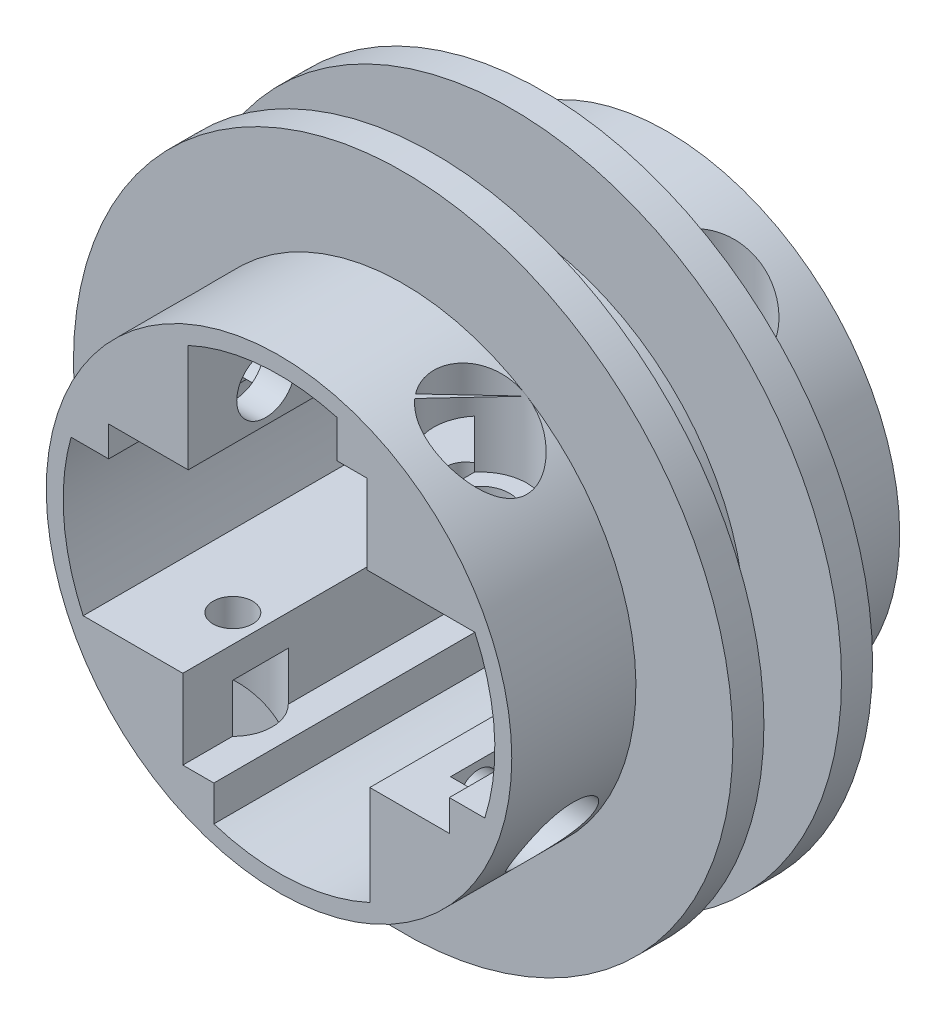
from build123d import *
from build123d.topology import SkipClean

# Parameters (mm, degrees)
SKETCH1_R            = 30
SKETCH1_R_2          = 27.819913731
BOSS_EXTRUDE2_DEPTH  = 16
SKETCH2_R            = 3.6
CUT_EXTRUDE1_DEPTH   = 16
SKETCH3_R            = 3.6
CUT_EXTRUDE2_DEPTH   = 16
SKETCH4_R            = 2.55
CUT_EXTRUDE3_DEPTH   = 16
SKETCH5_R            = 2.55
CUT_EXTRUDE4_DEPTH   = 16
SKETCH6_R            = 6
CUT_EXTRUDE5_DEPTH   = 10.75
SKETCH8_R            = 6
CUT_EXTRUDE6_DEPTH   = 10.75
SKETCH9_R            = 5.05
CUT_EXTRUDE7_DEPTH   = 9.78
SKETCH10_R           = 5.05
CUT_EXTRUDE9_DEPTH   = 9.78
SKETCH12_R           = 30
BOSS_EXTRUDE3_DEPTH  = 7
SKETCH13_R           = 30
BOSS_EXTRUDE4_DEPTH  = 3
SKETCH14_R           = 42.5
SKETCH14_R_2         = 27.819913731
BOSS_EXTRUDE5_DEPTH  = 3
SKETCH15_R           = 30
BOSS_EXTRUDE6_DEPTH  = 3
SKETCH16_R           = 42.5
SKETCH16_R_2         = 27.819913731
BOSS_EXTRUDE7_DEPTH  = 3
SKETCH17_R           = 29.9
SKETCH17_R_2         = 28.5
BOSS_EXTRUDE8_DEPTH  = 17
SKETCH18_R           = 29.9
SKETCH18_R_2         = 28.5
BOSS_EXTRUDE9_DEPTH  = 17
CUT_EXTRUDE10_REACH  = 93.507
SKETCH20_W           = 3.9
SKETCH20_H           = 10.25
SKETCH20_W_2         = 10.25
SKETCH20_H_2         = 4
SKETCH20_W_3         = 4
SKETCH20_H_3         = 3.9
SKETCH21_R           = 1
CUT_EXTRUDE11_DEPTH  = 10
SKETCH22_R           = 42.5
SKETCH22_R_2         = 29.9
BOSS_EXTRUDE10_DEPTH = 4
SKETCH23_R           = 42.5
SKETCH23_R_2         = 29.9
CUT_EXTRUDE12_DEPTH  = 4
SKETCH24_R           = 42.5
SKETCH24_R_2         = 30
BOSS_EXTRUDE11_DEPTH = 4
SKETCH26_R           = 42.5
SKETCH26_R_2         = 29.9
CUT_EXTRUDE13_DEPTH  = 4
SKETCH27_R           = 30
SKETCH27_R_2         = 29.9
BOSS_EXTRUDE13_DEPTH = 21
SKETCH28_R           = 30
SKETCH28_R_2         = 29.9
BOSS_EXTRUDE14_DEPTH = 21
SKETCH29_R           = 36.281043967
CUT_EXTRUDE14_DEPTH  = 18
SKETCH30_R           = 33.176266982
CUT_EXTRUDE15_DEPTH  = 18
SKETCH31_R           = 1
CUT_EXTRUDE16_DEPTH  = 10
SKETCH33_R           = 6
SKETCH33_R_2         = 3.6
CUT_EXTRUDE17_DEPTH  = 3.25
SKETCH34_R           = 5.05
SKETCH34_R_2         = 2.55
CUT_EXTRUDE18_DEPTH  = 4.22
SKETCH35_R           = 5.05
SKETCH35_R_2         = 2.55
CUT_EXTRUDE19_DEPTH  = 4.22
SKETCH37_R           = 6
SKETCH37_R_2         = 3.6
CUT_EXTRUDE20_DEPTH  = 3.25
SKETCH38_R           = 3.75
CUT_EXTRUDE21_DEPTH  = 5
SKETCH39_R           = 3.75
CUT_EXTRUDE22_DEPTH  = 5


with BuildPart() as part:
    # Sketch1 → Boss-Extrude2 (new body)
    with BuildSketch(Plane.XY):
        Circle(SKETCH1_R)
        Circle(SKETCH1_R_2, mode=Mode.SUBTRACT)
        with BuildLine():
            Line((11.7, -8.4), (11.7, -25.24))
            ThreePointArc((11.7, -25.24), (20.883398059, -18.380187309), (26.521455465, -8.4))
            Line((26.521455465, -8.4), (11.7, -8.4))
        make_face()
        with BuildLine():
            Line((-8.4, -11.7), (-25.24, -11.7))
            ThreePointArc((-25.24, -11.7), (-18.380187309, -20.883398059), (-8.4, -26.521455465))
            Line((-8.4, -26.521455465), (-8.4, -11.7))
        make_face()
        with BuildLine():
            Line((-26.803826219, 7.45), (-11.7, 7.45))
            Line((-11.7, 7.45), (-11.7, 25.24))
            ThreePointArc((-11.7, 25.24), (-21.207479421, 18.005288574), (-26.803826219, 7.45))
        make_face()
        with BuildLine():
            ThreePointArc((25.24, 11.7), (18.005288574, 21.207479421), (7.45, 26.803826219))
            Line((7.45, 26.803826219), (7.45, 11.7))
            Line((7.45, 11.7), (25.24, 11.7))
        make_face()
    extrude(amount=BOSS_EXTRUDE2_DEPTH)

    # Sketch2 → Cut-Extrude1 (cut)
    with BuildSketch(Plane(origin=(-11.7, 0, 0), x_dir=(0, 0, -1), z_dir=(1, 0, 0))):
        with Locations((-8, 15.95)):
            Circle(SKETCH2_R)
    extrude(amount=-CUT_EXTRUDE1_DEPTH, mode=Mode.SUBTRACT)

    # Sketch3 → Cut-Extrude2 (cut)
    with BuildSketch(Plane.XZ.offset(-11.7)):
        with Locations((15.95, 8)):
            Circle(SKETCH3_R)
    extrude(amount=-CUT_EXTRUDE2_DEPTH, mode=Mode.SUBTRACT)

    # Sketch4 → Cut-Extrude3 (cut)
    with BuildSketch(Plane(origin=(0, -11.7, 0), x_dir=(1, 0, 0), z_dir=(0, 1, 0))):
        with Locations(Location((-15.95, -8, 0), (0, 0, 180))):
            Circle(SKETCH4_R)
    extrude(amount=-CUT_EXTRUDE3_DEPTH, mode=Mode.SUBTRACT)

    # Sketch5 → Cut-Extrude4 (cut)
    with BuildSketch(Plane.ZY.offset(-11.7)):
        with Locations(Location((8, -15.95, 0), (0, 0, 270))):
            Circle(SKETCH5_R)
    extrude(amount=-CUT_EXTRUDE4_DEPTH, mode=Mode.SUBTRACT)

    # Sketch6 → Cut-Extrude5 (cut)
    with BuildSketch(Plane(origin=(-29.7, 0, 0), x_dir=(0, 0, -1), z_dir=(1, 0, 0))):
        with Locations(Location((-8, 15.95, 0), (0, 0, 180))):
            Circle(SKETCH6_R)
    extrude(amount=CUT_EXTRUDE5_DEPTH, mode=Mode.SUBTRACT)

    # Sketch8 → Cut-Extrude6 (cut)
    with BuildSketch(Plane(origin=(0, 29.7, 0), x_dir=(-1, 0, 0), z_dir=(0, -1, 0))):
        with Locations((-15.95, -8)):
            Circle(SKETCH8_R)
    extrude(amount=CUT_EXTRUDE6_DEPTH, mode=Mode.SUBTRACT)

    # Sketch9 → Cut-Extrude7 (cut)
    with BuildSketch(Plane.ZY.offset(-29.7)):
        with Locations(Location((8, -15.95, 0), (0, 0, 90))):
            Circle(SKETCH9_R)
    extrude(amount=CUT_EXTRUDE7_DEPTH, mode=Mode.SUBTRACT)

    # Sketch10 → Cut-Extrude9 (cut)
    with BuildSketch(Plane(origin=(0, -29.7, 0), x_dir=(1, 0, 0), z_dir=(0, 1, 0))):
        with Locations((-15.95, -8)):
            Circle(SKETCH10_R)
    extrude(amount=CUT_EXTRUDE9_DEPTH, mode=Mode.SUBTRACT)

    # Sketch12 → Boss-Extrude3 (add)
    with BuildSketch(Plane.XY.offset(16)):
        Circle(SKETCH12_R)
        with BuildLine():
            Line((7.45, 26.803826219), (7.45, 11.7))
            Line((7.45, 11.7), (25.24, 11.7))
            ThreePointArc((25.24, 11.7), (27.763547467, 1.770037295), (26.521455465, -8.4))
            Line((26.521455465, -8.4), (11.7, -8.4))
            Line((11.7, -8.4), (11.7, -25.24))
            ThreePointArc((11.7, -25.24), (1.770037295, -27.763547467), (-8.4, -26.521455465))
            Line((-8.4, -26.521455465), (-8.4, -11.7))
            Line((-8.4, -11.7), (-25.24, -11.7))
            ThreePointArc((-25.24, -11.7), (-27.727614158, -2.264290863), (-26.803826219, 7.45))
            Line((-26.803826219, 7.45), (-11.7, 7.45))
            Line((-11.7, 7.45), (-11.7, 25.24))
            ThreePointArc((-11.7, 25.24), (-2.264290863, 27.727614158), (7.45, 26.803826219))
        make_face(mode=Mode.SUBTRACT)
    extrude(amount=BOSS_EXTRUDE3_DEPTH)

    # Mirror2: part across plane


with BuildPart() as part_1:
    add(part.part)
    add(part.part.mirror(Plane.XY.offset(23)))

    # Sketch13 → Boss-Extrude4 (add)
    with BuildSketch(Plane.XY.offset(46)):
        Circle(SKETCH13_R)
        with BuildLine():
            Line((7.45, 11.7), (7.45, 26.803826219))
            ThreePointArc((7.45, 26.803826219), (-2.264290863, 27.727614158), (-11.7, 25.24))
            Line((-11.7, 25.24), (-11.7, 7.45))
            Line((-11.7, 7.45), (-26.803826219, 7.45))
            ThreePointArc((-26.803826219, 7.45), (-27.727614158, -2.264290863), (-25.24, -11.7))
            Line((-25.24, -11.7), (-8.4, -11.7))
            Line((-8.4, -11.7), (-8.4, -26.521455465))
            ThreePointArc((-8.4, -26.521455465), (1.770037295, -27.763547467), (11.7, -25.24))
            Line((11.7, -25.24), (11.7, -8.4))
            Line((11.7, -8.4), (26.521455465, -8.4))
            ThreePointArc((26.521455465, -8.4), (27.763547467, 1.770037295), (25.24, 11.7))
            Line((25.24, 11.7), (7.45, 11.7))
        make_face(mode=Mode.SUBTRACT)
    extrude(amount=BOSS_EXTRUDE4_DEPTH)

    # Sketch14 → Boss-Extrude5 (add)
    with BuildSketch(Plane.XY.offset(49)):
        Circle(SKETCH14_R)
        Circle(SKETCH14_R_2, mode=Mode.SUBTRACT)
    extrude(amount=-BOSS_EXTRUDE5_DEPTH)

    # Sketch15 → Boss-Extrude6 (add)
    with BuildSketch(Plane(origin=(0, 0, 0), x_dir=(-1, 0, 0), z_dir=(0, 0, -1))):
        Circle(SKETCH15_R)
        with BuildLine():
            Line((11.7, 7.45), (11.7, 25.24))
            ThreePointArc((11.7, 25.24), (2.264290863, 27.727614158), (-7.45, 26.803826219))
            Line((-7.45, 26.803826219), (-7.45, 11.7))
            Line((-7.45, 11.7), (-25.24, 11.7))
            ThreePointArc((-25.24, 11.7), (-27.763547467, 1.770037295), (-26.521455465, -8.4))
            Line((-26.521455465, -8.4), (-11.7, -8.4))
            Line((-11.7, -8.4), (-11.7, -25.24))
            ThreePointArc((-11.7, -25.24), (-1.770037295, -27.763547467), (8.4, -26.521455465))
            Line((8.4, -26.521455465), (8.4, -11.7))
            Line((8.4, -11.7), (25.24, -11.7))
            ThreePointArc((25.24, -11.7), (27.727614158, -2.264290863), (26.803826219, 7.45))
            Line((26.803826219, 7.45), (11.7, 7.45))
        make_face(mode=Mode.SUBTRACT)
    extrude(amount=BOSS_EXTRUDE6_DEPTH)

    # Sketch16 → Boss-Extrude7 (add)
    with BuildSketch(Plane(origin=(0, 0, -3), x_dir=(-1, 0, 0), z_dir=(0, 0, -1))):
        with Locations(Location((0, 0, 0), (0, 0, 180))):
            Circle(SKETCH16_R)
        Circle(SKETCH16_R_2, mode=Mode.SUBTRACT)
    extrude(amount=-BOSS_EXTRUDE7_DEPTH)

    # Sketch17 → Boss-Extrude8 (add)
    with BuildSketch(Plane(origin=(0, 0, -3), x_dir=(-1, 0, 0), z_dir=(0, 0, -1))):
        Circle(SKETCH17_R)
        Circle(SKETCH17_R_2, mode=Mode.SUBTRACT)
    extrude(amount=BOSS_EXTRUDE8_DEPTH)

    # Sketch18 → Boss-Extrude9 (add)
    with BuildSketch(Plane.XY.offset(49)):
        with Locations(Location((0, 0, 0), (0, 0, 180))):
            Circle(SKETCH18_R)
        with Locations(Location((0, 0, 0), (0, 0, 180))):
            Circle(SKETCH18_R_2, mode=Mode.SUBTRACT)
    extrude(amount=BOSS_EXTRUDE9_DEPTH)

    # Sketch20 → Cut-Extrude10 (cut, up to next)
    with BuildSketch(Plane.XY.offset(49), mode=Mode.PRIVATE) as cut_extrude10_sk1:
        with Locations((9.4, 16.825)):
            Rectangle(SKETCH20_W, SKETCH20_H)
    cut_extrude10_tool1 = extrude(cut_extrude10_sk1.sketch, amount=-CUT_EXTRUDE10_REACH, mode=Mode.PRIVATE) & part_1.part
    # Sketch20 → Cut-Extrude10 (cut, up to next)
    with BuildSketch(Plane.XY.offset(49), mode=Mode.PRIVATE) as cut_extrude10_sk2:
        with Locations((16.825, -10.4)):
            Rectangle(SKETCH20_W_2, SKETCH20_H_2)
    cut_extrude10_tool2 = extrude(cut_extrude10_sk2.sketch, amount=-CUT_EXTRUDE10_REACH, mode=Mode.PRIVATE) & part_1.part
    # Sketch20 → Cut-Extrude10 (cut, up to next)
    with BuildSketch(Plane.XY.offset(49), mode=Mode.PRIVATE) as cut_extrude10_sk3:
        with Locations((-10.4, -16.825)):
            Rectangle(SKETCH20_W_3, SKETCH20_H)
    cut_extrude10_tool3 = extrude(cut_extrude10_sk3.sketch, amount=-CUT_EXTRUDE10_REACH, mode=Mode.PRIVATE) & part_1.part
    # Sketch20 → Cut-Extrude10 (cut, up to next)
    with BuildSketch(Plane.XY.offset(49), mode=Mode.PRIVATE) as cut_extrude10_sk4:
        with Locations((-16.825, 9.4)):
            Rectangle(SKETCH20_W_2, SKETCH20_H_3)
    cut_extrude10_tool4 = extrude(cut_extrude10_sk4.sketch, amount=-CUT_EXTRUDE10_REACH, mode=Mode.PRIVATE) & part_1.part
    add(cut_extrude10_tool1.solids().sort_by_distance((9.4, 16.825, 49))[0], mode=Mode.SUBTRACT)
    add(cut_extrude10_tool2.solids().sort_by_distance((16.825, -10.4, 49))[0], mode=Mode.SUBTRACT)
    add(cut_extrude10_tool3.solids().sort_by_distance((-10.4, -16.825, 49))[0], mode=Mode.SUBTRACT)
    add(cut_extrude10_tool4.solids().sort_by_distance((-16.825, 9.4, 49))[0], mode=Mode.SUBTRACT)

    # Sketch21 → Cut-Extrude11 (cut)
    with SkipClean():  # the faces are left unmerged after this step: merging them gives an invalid solid
        with BuildSketch(Plane(origin=(0, 30, 0), x_dir=(1, 0, 0), z_dir=(0, 1, 0))):
            with Locations(Location((-3, -23, 0), (0, 0, 270))):
                Circle(SKETCH21_R)
        extrude(amount=-CUT_EXTRUDE11_DEPTH, mode=Mode.SUBTRACT)

    # Sketch22 → Boss-Extrude10 (add)
    with SkipClean():  # the faces are left unmerged after this step: merging them gives an invalid solid
        with BuildSketch(Plane(origin=(0, 0, 32), x_dir=(-1, 0, 0), z_dir=(0, 0, -1))):
            with Locations(Location((0, 0, 0), (0, 0, 180))):
                Circle(SKETCH22_R)
            Circle(SKETCH22_R_2, mode=Mode.SUBTRACT)
        extrude(amount=BOSS_EXTRUDE10_DEPTH)

    # Sketch23 → Cut-Extrude12 (cut)
    with SkipClean():  # the faces are left unmerged after this step: merging them gives an invalid solid
        with BuildSketch(Plane(origin=(0, 0, 46), x_dir=(-1, 0, 0), z_dir=(0, 0, -1))):
            Circle(SKETCH23_R)
            Circle(SKETCH23_R_2, mode=Mode.SUBTRACT)
        extrude(amount=-CUT_EXTRUDE12_DEPTH, mode=Mode.SUBTRACT)

    # Sketch24 → Boss-Extrude11 (add)
    with SkipClean():  # the faces are left unmerged after this step: merging them gives an invalid solid
        with BuildSketch(Plane.XY.offset(14)):
            with Locations(Location((0, 0, 0), (0, 0, 180))):
                Circle(SKETCH24_R)
            with Locations(Location((0, 0, 0), (0, 0, 180))):
                Circle(SKETCH24_R_2, mode=Mode.SUBTRACT)
        extrude(amount=BOSS_EXTRUDE11_DEPTH)

    # Sketch26 → Cut-Extrude13 (cut)
    with SkipClean():  # the faces are left unmerged after this step: merging them gives an invalid solid
        with BuildSketch(Plane.XY):
            with Locations(Location((0, 0, 0), (0, 0, 180))):
                Circle(SKETCH26_R)
            Circle(SKETCH26_R_2, mode=Mode.SUBTRACT)
        extrude(amount=-CUT_EXTRUDE13_DEPTH, mode=Mode.SUBTRACT)

    # Sketch27 → Boss-Extrude13 (add)
    with SkipClean():  # the faces are left unmerged after this step: merging them gives an invalid solid
        with BuildSketch(Plane.XY.offset(66)):
            with Locations(Location((0, 0, 0), (0, 0, 147.881865907))):
                Circle(SKETCH27_R)
            Circle(SKETCH27_R_2, mode=Mode.SUBTRACT)
        extrude(amount=-BOSS_EXTRUDE13_DEPTH)

    # Sketch28 → Boss-Extrude14 (add)
    with BuildSketch(Plane(origin=(0, 0, -20), x_dir=(-1, 0, 0), z_dir=(0, 0, -1))):
        Circle(SKETCH28_R)
        Circle(SKETCH28_R_2, mode=Mode.SUBTRACT)
    extrude(amount=-BOSS_EXTRUDE14_DEPTH)

    # Sketch29 → Cut-Extrude14 (cut)
    with BuildSketch(Plane(origin=(0, 0, -20), x_dir=(-1, 0, 0), z_dir=(0, 0, -1))):
        Circle(SKETCH29_R)
    extrude(amount=-CUT_EXTRUDE14_DEPTH, mode=Mode.SUBTRACT)

    # Sketch30 → Cut-Extrude15 (cut)
    with BuildSketch(Plane.XY.offset(66)):
        Circle(SKETCH30_R)
    extrude(amount=-CUT_EXTRUDE15_DEPTH, mode=Mode.SUBTRACT)

    # Sketch31 → Cut-Extrude16 (cut)
    with BuildSketch(Plane(origin=(0, 30, 0), x_dir=(1, 0, 0), z_dir=(0, 1, 0))):
        with Locations(Location((4, -23, 0), (0, 0, 270))):
            Circle(SKETCH31_R)
    extrude(amount=-CUT_EXTRUDE16_DEPTH, mode=Mode.SUBTRACT)

    # Sketch33 → Cut-Extrude17 (cut)
    with BuildSketch(Plane.ZY.offset(18.95)):
        with Locations((8, 15.95)):
            Circle(SKETCH33_R)
        with Locations(Location((8, 15.95, 0), (0, 0, 180))):
            Circle(SKETCH33_R_2, mode=Mode.SUBTRACT)
        with Locations(Location((38, 15.95, 0), (0, 0, 180))):
            Circle(SKETCH33_R)
        with Locations((38, 15.95)):
            Circle(SKETCH33_R_2, mode=Mode.SUBTRACT)
    extrude(amount=-CUT_EXTRUDE17_DEPTH, mode=Mode.SUBTRACT)

    # Sketch34 → Cut-Extrude18 (cut)
    with BuildSketch(Plane.XZ.offset(19.92)):
        with Locations((-15.95, 38)):
            Circle(SKETCH34_R)
        with Locations(Location((-15.95, 38, 0), (0, 0, 180))):
            Circle(SKETCH34_R_2, mode=Mode.SUBTRACT)
        with Locations((-15.95, 8)):
            Circle(SKETCH34_R)
        with Locations(Location((-15.95, 8, 0), (0, 0, 180))):
            Circle(SKETCH34_R_2, mode=Mode.SUBTRACT)
    extrude(amount=-CUT_EXTRUDE18_DEPTH, mode=Mode.SUBTRACT)

    # Sketch35 → Cut-Extrude19 (cut)
    with BuildSketch(Plane(origin=(19.92, 0, 0), x_dir=(0, 0, -1), z_dir=(1, 0, 0))):
        with Locations(Location((-38, -15.95, 0), (0, 0, 90))):
            Circle(SKETCH35_R)
        with Locations(Location((-38, -15.95, 0), (0, 0, 270))):
            Circle(SKETCH35_R_2, mode=Mode.SUBTRACT)
        with Locations(Location((-8, -15.95, 0), (0, 0, 90))):
            Circle(SKETCH35_R)
        with Locations(Location((-8, -15.95, 0), (0, 0, 270))):
            Circle(SKETCH35_R_2, mode=Mode.SUBTRACT)
    extrude(amount=-CUT_EXTRUDE19_DEPTH, mode=Mode.SUBTRACT)

    # Sketch37 → Cut-Extrude20 (cut)
    with BuildSketch(Plane(origin=(0, 18.95, 0), x_dir=(1, 0, 0), z_dir=(0, 1, 0))):
        with Locations(Location((15.95, -38, 0), (0, 0, 219.94450519))):
            Circle(SKETCH37_R)
        with Locations((15.95, -38)):
            Circle(SKETCH37_R_2, mode=Mode.SUBTRACT)
        with Locations(Location((15.95, -8, 0), (0, 0, 219.94450519))):
            Circle(SKETCH37_R)
        with Locations((15.95, -8)):
            Circle(SKETCH37_R_2, mode=Mode.SUBTRACT)
    extrude(amount=-CUT_EXTRUDE20_DEPTH, mode=Mode.SUBTRACT)

    # Sketch38 → Cut-Extrude21 (cut)
    with BuildSketch(Plane(origin=(0, 15.7, 0), x_dir=(1, 0, 0), z_dir=(0, 1, 0))):
        with Locations(Location((15.95, -38, 0), (0, 0, 180))):
            Circle(SKETCH38_R)
        with Locations(Location((15.95, -8, 0), (0, 0, 180))):
            Circle(SKETCH38_R)
    extrude(amount=-CUT_EXTRUDE21_DEPTH, mode=Mode.SUBTRACT)

    # Sketch39 → Cut-Extrude22 (cut)
    with BuildSketch(Plane.ZY.offset(15.7)):
        with Locations((38, 15.95)):
            Circle(SKETCH39_R)
        with Locations((8, 15.95)):
            Circle(SKETCH39_R)
    extrude(amount=-CUT_EXTRUDE22_DEPTH, mode=Mode.SUBTRACT)


solid = part_1.part
